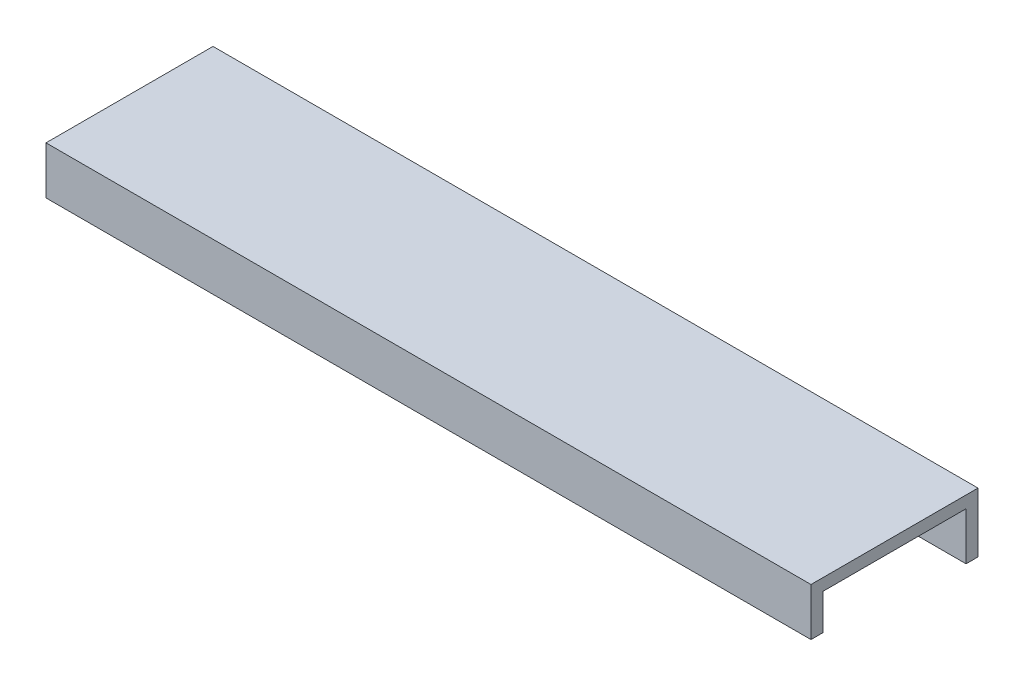
from build123d import *

# Parameters (mm, degrees)
ESQUISSE1_W        = 128.24605794
ESQUISSE1_H        = 10
BOSS_EXTRU_2_DEPTH = 2
ESQUISSE2_W        = 128.24605794
ESQUISSE2_H        = 2
BOSS_EXTRU_3_DEPTH = 24
ESQUISSE3_W        = 128.24605794
ESQUISSE3_H        = 8
BOSS_EXTRU_4_DEPTH = 2


with BuildPart() as part:
    # Esquisse1 → Boss.-Extru.2 (new body)
    with BuildSketch(Plane.XY):
        with Locations((-64.12703781, 124.040016289)):
            Rectangle(ESQUISSE1_W, ESQUISSE1_H)
    extrude(amount=BOSS_EXTRU_2_DEPTH)

    # Esquisse2 → Boss.-Extru.3 (add)
    with BuildSketch(Plane.XY.offset(2)):
        with Locations((-64.12703781, 128.040016289)):
            Rectangle(ESQUISSE2_W, ESQUISSE2_H)
    extrude(amount=BOSS_EXTRU_3_DEPTH)

    # Esquisse3 → Boss.-Extru.4 (add)
    with BuildSketch(Plane.XY.offset(26)):
        with Locations((-64.12703781, 125.040016289)):
            Rectangle(ESQUISSE3_W, ESQUISSE3_H)
    extrude(amount=BOSS_EXTRU_4_DEPTH)


solid = part.part
